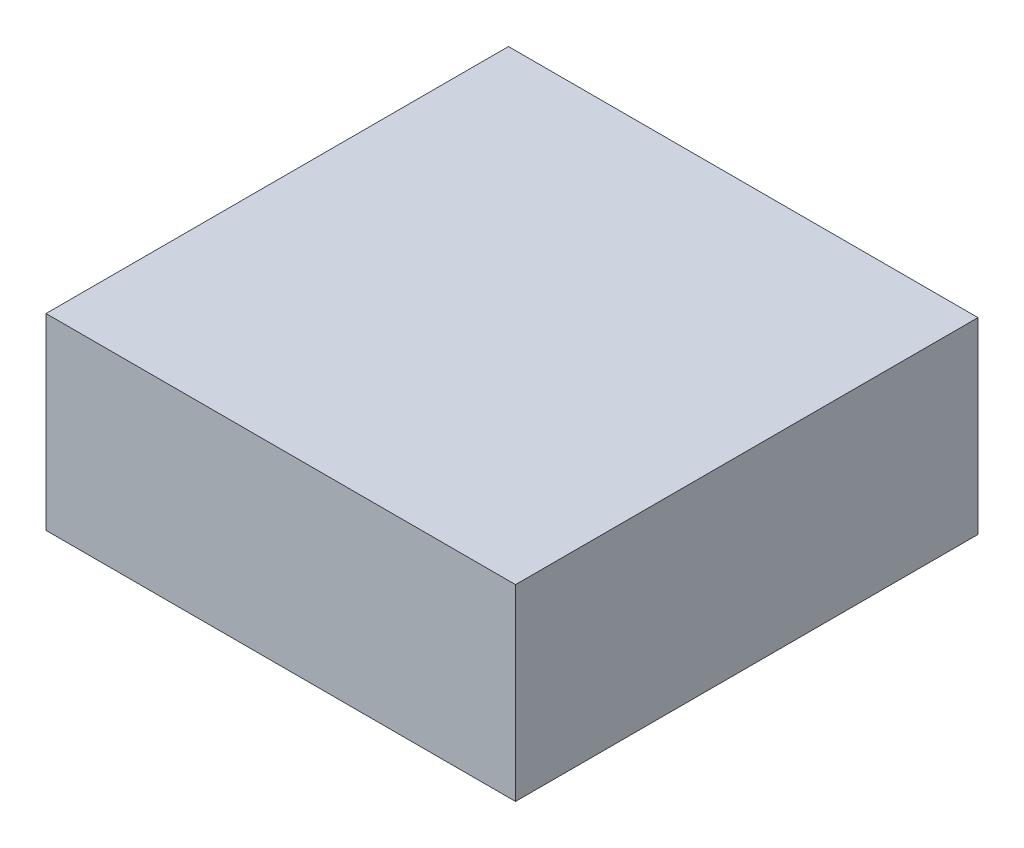
from build123d import *

# Parameters (mm, degrees)
SKETCH2_W           = 50.8
SKETCH2_H           = 50.038
BOSS_EXTRUDE1_DEPTH = 20.32


with BuildPart() as part:
    # Sketch2 → Boss-Extrude1 (new body)
    with BuildSketch(Plane(origin=(0, 0, 0), x_dir=(1, 0, 0), z_dir=(0, 1, 0))):
        with Locations((25.4, 25.019)):
            Rectangle(SKETCH2_W, SKETCH2_H)
    extrude(amount=BOSS_EXTRUDE1_DEPTH)


solid = part.part
